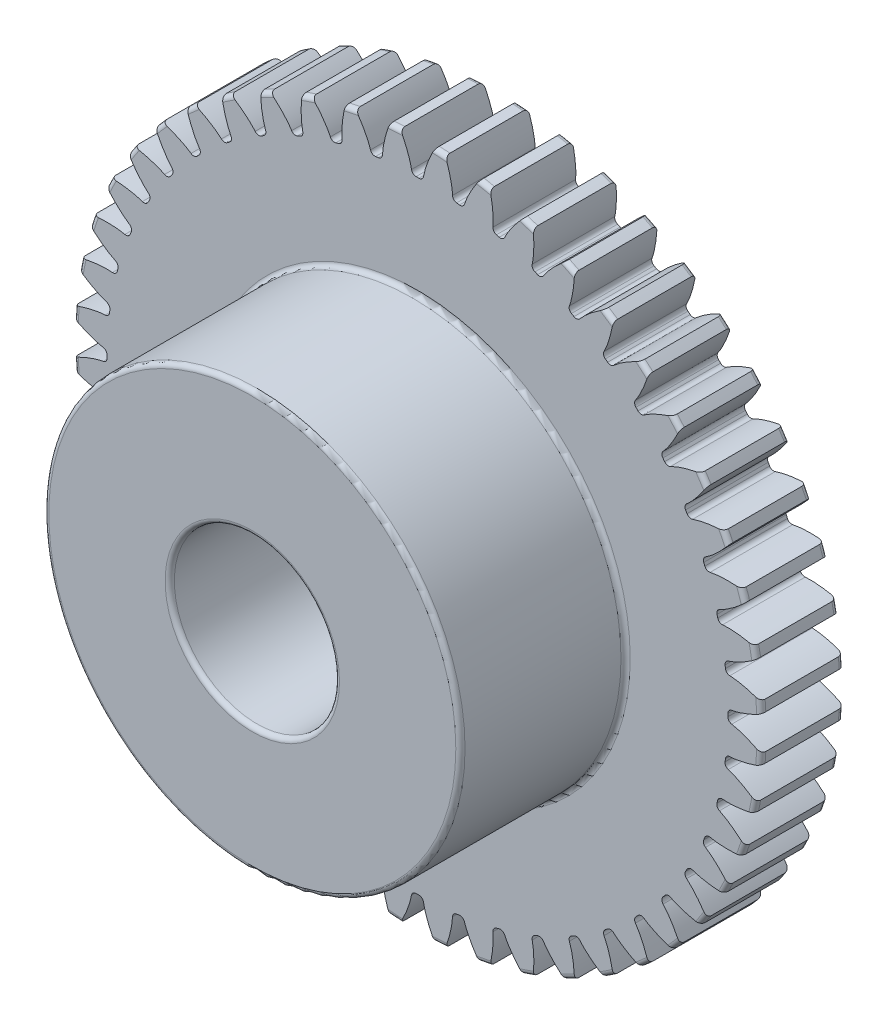
from build123d import *

# Parameters (mm, degrees)
SKETCH3_R                = 13.229166667
BOSS_EXTRUDE1_DEPTH      = 4.7625
BOSS_EXTRUDE1_DEPTH_BACK = 4.7625
SKETCH5_W                = 6.35
SKETCH5_H                = 5.228166667
SKETCH5_W_2              = 9.525
SKETCH5_H_2              = 3.175
FILLET2_R                = 0.177538081
CUT_EXTRUDE1_DEPTH       = 5.7625
FILLET1_R                = 0.177538081
CIRPATTERN1_COUNT        = 48
FILLET1_OF_CIRPATTERN1_R = 0.177538081


with BuildPart() as part:
    # Sketch3 → Boss-Extrude1 (new body, two sides)
    with BuildSketch(Plane.XY) as boss_extrude1_sk:
        Circle(SKETCH3_R)
    extrude(amount=BOSS_EXTRUDE1_DEPTH)
    extrude(boss_extrude1_sk.sketch, amount=-BOSS_EXTRUDE1_DEPTH_BACK)

    # Sketch5 → Cut-Revolve1 (revolve, cut)
    with BuildSketch(Plane(origin=(0, 0, 0), x_dir=(0, 0, -1), z_dir=(1, 0, 0))):
        with Locations((-1.5875, 10.615083334)):
            Rectangle(SKETCH5_W, SKETCH5_H)
        with Locations((0, 1.5875)):
            Rectangle(SKETCH5_W_2, SKETCH5_H_2)
    revolve(axis=Axis((0, 0, 4.7625), (0, 0, -1)), mode=Mode.SUBTRACT)

    # Fillet2
    fillet2_edges = [part.edges().sort_by_distance(p)[0] for p in [
        (0, -3.175, 4.7625),
        (0, -3.175, -4.7625),
        (0, -8.001, 4.7625),
        (0, -8.001, -1.5875),
        (-13.229166667, 0, -1.5875),
        (-13.229166667, 0, -4.7625),
    ]]
    fillet(fillet2_edges, radius=FILLET2_R)

    # Sketch4 → Cut-Extrude1 (cut, symmetric)
    with BuildSketch(Plane.XY):
        with BuildLine():
            ThreePointArc((11.932074389, 0.212658516), (11.933969284, 0), (11.932201369, -0.212660779))
            add(Edge.make_bspline(
                [(11.932201369, -0.212660779), (11.934219485, -0.212717179), (11.939878545, -0.212938639), (11.950572169, -0.213607197), (11.96801338, -0.215053108), (11.990223234, -0.217417388), (12.018912857, -0.221072811), (12.052685397, -0.226150351), (12.089772396, -0.232538871), (12.130087993, -0.240362214), (12.170276341, -0.24893927), (12.21033352, -0.258214333), (12.250205367, -0.268102395), (12.298462883, -0.280846952), (12.356270454, -0.297195047), (12.423746985, -0.317857891), (12.500161506, -0.343127611), (12.577910666, -0.370845697), (12.654305415, -0.399734381), (12.731356883, -0.43078019), (12.805811965, -0.462134729), (12.883001062, -0.496607647), (12.954175712, -0.529396299), (13.033746126, -0.568241958), (13.097910552, -0.600206527), (13.164044277, -0.634987314), (13.196210008, -0.652175364), (13.21263934, -0.661069106)],
                knots=[0, 0, 0, 0, 0, 0.005376749, 0.015083688, 0.02853182, 0.04661014, 0.064854849, 0.092110526, 0.119476176, 0.146842496, 0.174208854, 0.201574956, 0.228941013, 0.256307345, 0.307035032, 0.361767352, 0.416499661, 0.471231937, 0.525964282, 0.580696616, 0.635428982, 0.690161387, 0.744893688, 0.799626082, 0.854358407, 0.909090914, 0.909090914, 0.909090914, 0.909090914, 0.909090914], degree=4))
            ThreePointArc((13.21263934, -0.661069106), (13.229166667, 0), (13.21263934, 0.661069106))
            add(Edge.make_bspline(
                [(11.932074389, 0.212658516), (11.934219485, 0.212717179), (11.939878545, 0.212938639), (11.950572169, 0.213607197), (11.96801338, 0.215053108), (11.990223234, 0.217417388), (12.018912857, 0.221072811), (12.052685397, 0.226150351), (12.089772396, 0.232538871), (12.130087993, 0.240362214), (12.170276341, 0.24893927), (12.21033352, 0.258214333), (12.250205367, 0.268102395), (12.298462883, 0.280846952), (12.356270454, 0.297195047), (12.423746985, 0.317857891), (12.500161506, 0.343127611), (12.577910666, 0.370845697), (12.654305415, 0.399734381), (12.731356883, 0.43078019), (12.805811965, 0.462134729), (12.883001062, 0.496607647), (12.954175712, 0.529396299), (13.033746126, 0.568241958), (13.097910552, 0.600206527), (13.164044277, 0.634987314), (13.196210008, 0.652175364), (13.21263934, 0.661069106)],
                knots=[0, 0, 0, 0, 0, 0.005376749, 0.015083688, 0.02853182, 0.04661014, 0.064854849, 0.092110526, 0.119476176, 0.146842496, 0.174208854, 0.201574956, 0.228941013, 0.256307345, 0.307035032, 0.361767352, 0.416499661, 0.471231937, 0.525964282, 0.580696616, 0.635428982, 0.690161387, 0.744893688, 0.799626082, 0.854358407, 0.909090914, 0.909090914, 0.909090914, 0.909090914, 0.909090914], degree=4))
        make_face()
    cut_extrude1 = extrude(amount=CUT_EXTRUDE1_DEPTH, both=True, mode=Mode.SUBTRACT)

    # Fillet1
    fillet1_edges = [part.edges().sort_by_distance(p)[0] for p in [
        (11.932201369, -0.212660779, -3.175),
        (11.932074389, 0.212658516, -3.175),
    ]]
    fillet(fillet1_edges, radius=FILLET1_R)

    # CirPattern1: Cut-Extrude1 ×48 about axis
    cirpattern1_axis = Axis((0, 0, 4.7625), (0, 0, -1))
    for i in range(1, CIRPATTERN1_COUNT):
        add(cut_extrude1.rotate(cirpattern1_axis, i * 360 / CIRPATTERN1_COUNT), mode=Mode.SUBTRACT)

    # Fillet1 of CirPattern1
    fillet1_of_cirpattern1_edges = [part.edges().sort_by_distance(p)[0] for p in [
        (11.80236193, -1.768306246, -3.175),
        (11.857751345, -1.346609042, -3.175),
        (11.470580807, -3.293695503, -3.175),
        (11.580538888, -2.882835747, -3.175),
        (10.942534866, -4.762728717, -3.175),
        (11.105180199, -4.369736332, -3.175),
        (10.227259119, -6.150270322, -3.175),
        (10.439808799, -5.781869517, -3.175),
        (9.336992133, -7.432579096, -3.175),
        (9.595809375, -7.095073312, -3.175),
        (8.286966623, -8.587714382, -3.175),
        (8.587622993, -8.286878435, -3.175),
        (7.095148817, -9.595911493, -3.175),
        (7.4325, -9.336892771, -3.175),
        (5.781931047, -10.439919898, -3.175),
        (6.150204872, -10.227150283, -3.175),
        (4.369782834, -11.105298379, -3.175),
        (4.762678033, -10.942418418, -3.175),
        (2.882866425, -11.580662127, -3.175),
        (3.293660452, -11.47045874, -3.175),
        (1.346623373, -11.857877534, -3.175),
        (1.768287428, -11.802236332, -3.175),
        (-0.212660779, -11.932201369, -3.175),
        (0.212658516, -11.932074389, -3.175),
        (-1.768306246, -11.80236193, -3.175),
        (-1.346609042, -11.857751345, -3.175),
        (-3.293695503, -11.470580807, -3.175),
        (-2.882835747, -11.580538888, -3.175),
        (-4.762728717, -10.942534866, -3.175),
        (-4.369736332, -11.105180199, -3.175),
        (-6.150270322, -10.227259119, -3.175),
        (-5.781869517, -10.439808799, -3.175),
        (-7.432579096, -9.336992133, -3.175),
        (-7.095073312, -9.595809375, -3.175),
        (-8.587714382, -8.286966623, -3.175),
        (-8.286878435, -8.587622993, -3.175),
        (-9.595911493, -7.095148817, -3.175),
        (-9.336892771, -7.4325, -3.175),
        (-10.439919898, -5.781931047, -3.175),
        (-10.227150283, -6.150204872, -3.175),
        (-11.105298379, -4.369782834, -3.175),
        (-10.942418418, -4.762678033, -3.175),
        (-11.580662127, -2.882866425, -3.175),
        (-11.47045874, -3.293660452, -3.175),
        (-11.857877534, -1.346623373, -3.175),
        (-11.802236332, -1.768287428, -3.175),
        (-11.932201369, 0.212660779, -3.175),
        (-11.932074389, -0.212658516, -3.175),
        (-11.80236193, 1.768306246, -3.175),
        (-11.857751345, 1.346609042, -3.175),
        (-11.470580807, 3.293695503, -3.175),
        (-11.580538888, 2.882835747, -3.175),
        (-10.942534866, 4.762728717, -3.175),
        (-11.105180199, 4.369736332, -3.175),
        (-10.227259119, 6.150270322, -3.175),
        (-10.439808799, 5.781869517, -3.175),
        (-9.336992133, 7.432579096, -3.175),
        (-9.595809375, 7.095073312, -3.175),
        (-8.286966623, 8.587714382, -3.175),
        (-8.587622993, 8.286878435, -3.175),
        (-7.095148817, 9.595911493, -3.175),
        (-7.4325, 9.336892771, -3.175),
        (-5.781931047, 10.439919898, -3.175),
        (-6.150204872, 10.227150283, -3.175),
        (-4.369782834, 11.105298379, -3.175),
        (-4.762678033, 10.942418418, -3.175),
        (-2.882866425, 11.580662127, -3.175),
        (-3.293660452, 11.47045874, -3.175),
        (-1.346623373, 11.857877534, -3.175),
        (-1.768287428, 11.802236332, -3.175),
        (0.212660779, 11.932201369, -3.175),
        (-0.212658516, 11.932074389, -3.175),
        (1.768306246, 11.80236193, -3.175),
        (1.346609042, 11.857751345, -3.175),
        (3.293695503, 11.470580807, -3.175),
        (2.882835747, 11.580538888, -3.175),
        (4.762728717, 10.942534866, -3.175),
        (4.369736332, 11.105180199, -3.175),
        (6.150270322, 10.227259119, -3.175),
        (5.781869517, 10.439808799, -3.175),
        (7.432579096, 9.336992133, -3.175),
        (7.095073312, 9.595809375, -3.175),
        (8.587714382, 8.286966623, -3.175),
        (8.286878435, 8.587622993, -3.175),
        (9.595911493, 7.095148817, -3.175),
        (9.336892771, 7.4325, -3.175),
        (10.439919898, 5.781931047, -3.175),
        (10.227150283, 6.150204872, -3.175),
        (11.105298379, 4.369782834, -3.175),
        (10.942418418, 4.762678033, -3.175),
        (11.580662127, 2.882866425, -3.175),
        (11.47045874, 3.293660452, -3.175),
        (11.857877534, 1.346623373, -3.175),
        (11.802236332, 1.768287428, -3.175),
    ]]
    fillet(fillet1_of_cirpattern1_edges, radius=FILLET1_OF_CIRPATTERN1_R)


solid = part.part
